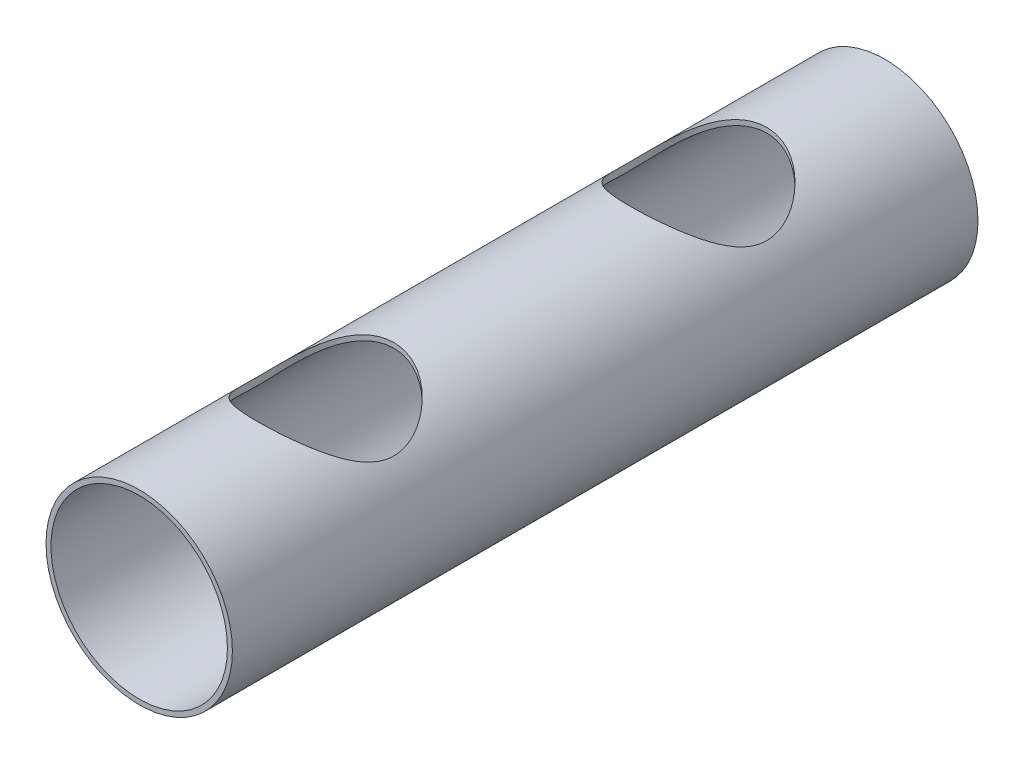
from build123d import *

# Parameters (mm, degrees)
SKETCH1_R           = 37.5
SKETCH1_R_2         = 35.5
BOSS_EXTRUDE1_DEPTH = 300
SKETCH2_R           = 27.5
CUT_EXTRUDE1_DEPTH  = 100


with BuildPart() as part:
    # Sketch1 → Boss-Extrude1 (new body)
    with BuildSketch(Plane.XY):
        Circle(SKETCH1_R)
        Circle(SKETCH1_R_2, mode=Mode.SUBTRACT)
    extrude(amount=BOSS_EXTRUDE1_DEPTH)

    # Sketch2 → Cut-Extrude1 (cut)
    with BuildSketch(Plane(origin=(0, 0, 0), x_dir=(1, 0, 0), z_dir=(0, 1, 0))):
        with Locations((0, -75)):
            Circle(SKETCH2_R)
        with Locations((0, -225)):
            Circle(SKETCH2_R)
    extrude(amount=CUT_EXTRUDE1_DEPTH, mode=Mode.SUBTRACT)


solid = part.part
